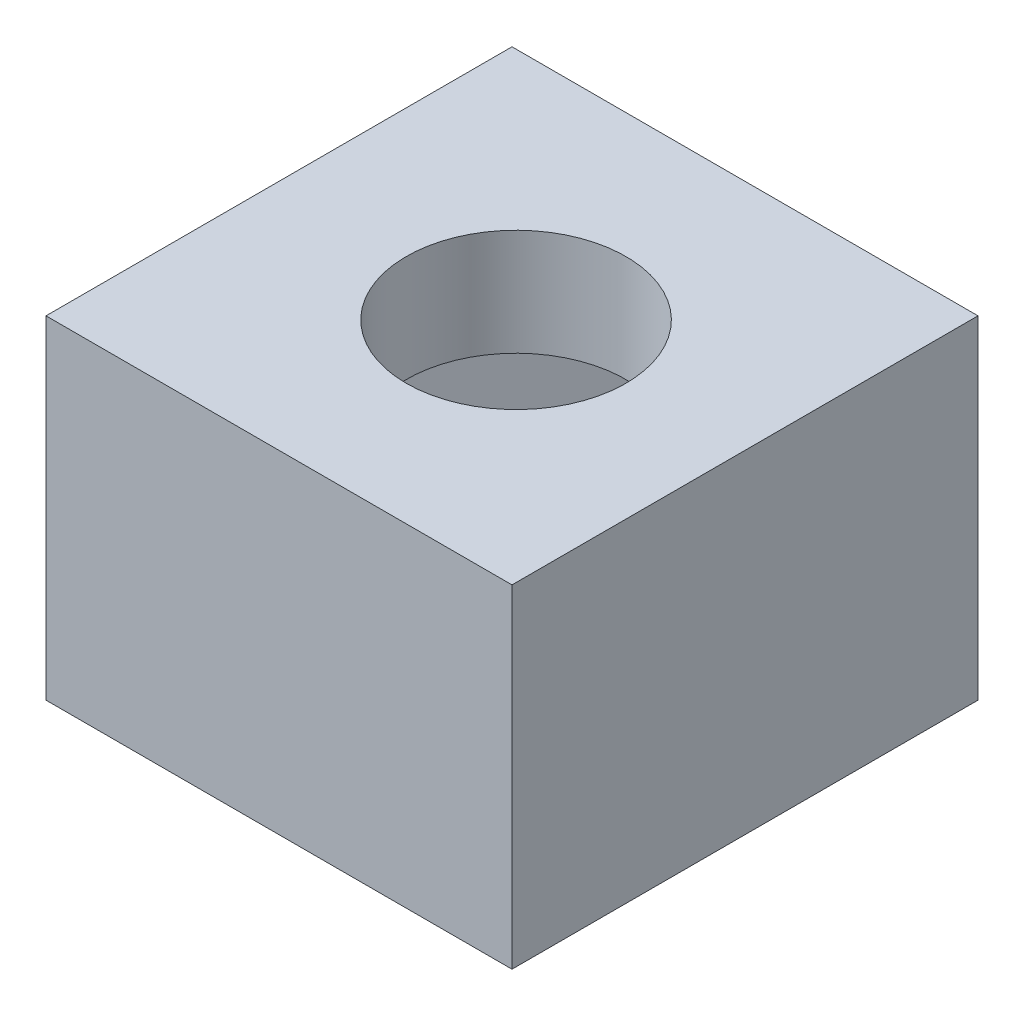
from build123d import *

# Parameters (mm, degrees)
SKETCH1_W           = 7
SKETCH1_H           = 7
BOSS_EXTRUDE1_DEPTH = 5
SKETCH4_R           = 1.65
CUT_EXTRUDE4_DEPTH  = 4
SKETCH6_R           = 1.65
CUT_EXTRUDE6_DEPTH  = 4
SKETCH6_4_R         = 1.65
BOSS_EXTRUDE2_DEPTH = 1.6


with BuildPart() as part:
    # Sketch1 → Boss-Extrude1 (new body)
    with BuildSketch(Plane(origin=(0, 0, 0), x_dir=(1, 0, 0), z_dir=(0, 1, 0))):
        with Locations((-0.67779661, -2.128287226)):
            Rectangle(SKETCH1_W, SKETCH1_H)
    extrude(amount=BOSS_EXTRUDE1_DEPTH)

    # Sketch4 → Cut-Extrude4 (cut)
    with BuildSketch(Plane(origin=(0, 5, 0), x_dir=(1, 0, 0), z_dir=(0, 1, 0))):
        Polygon((-1.416005829, 0.916524834), (-3.661371426, -1.328840764), (-2.839510577, -4.396067211), (0.22771587, -5.21792806), (2.473081468, -2.972562463), (1.651220618, 0.094663984), align=None)
        with Locations((-0.594144979, -2.150701613)):
            Circle(SKETCH4_R, mode=Mode.SUBTRACT)
    extrude(amount=-CUT_EXTRUDE4_DEPTH, mode=Mode.SUBTRACT)

    # Sketch6 → Cut-Extrude6 (cut)
    with BuildSketch(Plane(origin=(0, 5, 0), x_dir=(1, 0, 0), z_dir=(0, 1, 0))):
        with Locations((-0.594144979, -2.150701613)):
            Circle(SKETCH6_R)
    extrude(amount=-CUT_EXTRUDE6_DEPTH, mode=Mode.SUBTRACT)

    # Sketch6_4 → Boss-Extrude2 (add)
    with BuildSketch(Plane(origin=(0, 5, 0), x_dir=(1, 0, 0), z_dir=(0, 1, 0))):
        Polygon((-1.416005829, 0.916524834), (-3.661371426, -1.328840764), (-2.839510577, -4.396067211), (0.22771587, -5.21792806), (2.473081468, -2.972562463), (1.651220618, 0.094663984), align=None)
        with Locations((-0.594144979, -2.150701613)):
            Circle(SKETCH6_4_R, mode=Mode.SUBTRACT)
    extrude(amount=-BOSS_EXTRUDE2_DEPTH)


solid = part.part
